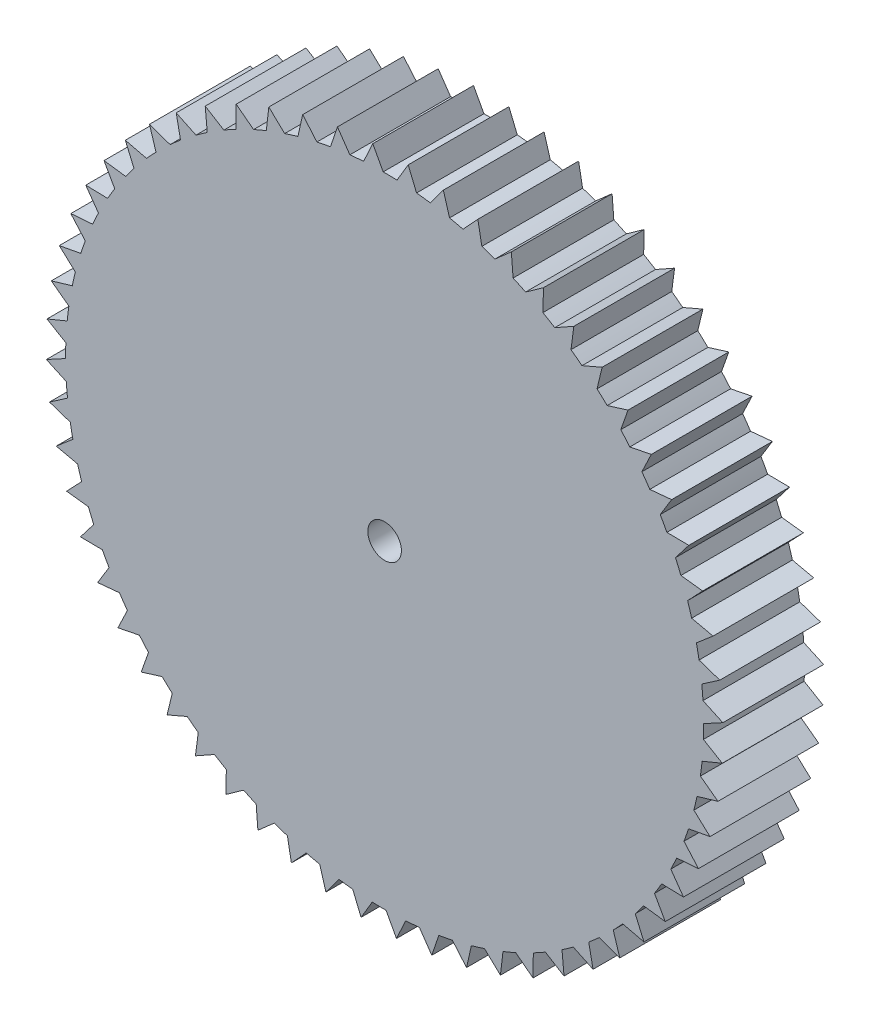
from build123d import *

# Parameters (mm, degrees)
SKETCH3_R           = 9.5
BOSS_EXTRUDE1_DEPTH = 3
SKETCH7_R           = 2
BOSS_EXTRUDE4_DEPTH = 3
BOSS_EXTRUDE5_DEPTH = 3
CIRPATTERN2_COUNT   = 20
SKETCH9_R           = 0.5
CUT_EXTRUDE1_DEPTH  = 6
BOSS_EXTRUDE6_DEPTH = 3
CIRPATTERN3_COUNT   = 60


with BuildPart() as part:
    # Sketch3 → Boss-Extrude1 (new body)
    with BuildSketch(Plane(origin=(0, 0, -25.970633743), x_dir=(-1, 0, 0), z_dir=(0, 0, -1))):
        with Locations((0, 66.2)):
            Circle(SKETCH3_R)
    extrude(amount=BOSS_EXTRUDE1_DEPTH)

    # Sketch7 → Boss-Extrude4 (add)
    with BuildSketch(Plane(origin=(0, 0, -28.970633743), x_dir=(-1, 0, 0), z_dir=(0, 0, -1))):
        with Locations((0, 66.2)):
            Circle(SKETCH7_R)
    extrude(amount=BOSS_EXTRUDE4_DEPTH)

    # Sketch8 → Boss-Extrude5 (add)
    with BuildSketch(Plane(origin=(0, 0, -31.970633743), x_dir=(-1, 0, 0), z_dir=(0, 0, -1))):
        Polygon((0.4, 64.4), (-0.4, 64.4), (0, 63.6), align=None)
    boss_extrude5 = extrude(amount=-BOSS_EXTRUDE5_DEPTH)

    # CirPattern2: Boss-Extrude5 ×20 about axis
    cirpattern2_axis = Axis((0, 66.168195033, 0), (0, 0, 1))
    for i in range(1, CIRPATTERN2_COUNT):
        add(boss_extrude5.rotate(cirpattern2_axis, i * 360 / CIRPATTERN2_COUNT))

    # Sketch9 → Cut-Extrude1 (cut)
    with BuildSketch(Plane(origin=(0, 0, -31.970633743), x_dir=(-1, 0, 0), z_dir=(0, 0, -1))):
        with Locations((0, 66.2)):
            Circle(SKETCH9_R)
    extrude(amount=-CUT_EXTRUDE1_DEPTH, mode=Mode.SUBTRACT)

    # Sketch10 → Boss-Extrude6 (add)
    with BuildSketch(Plane.XY.offset(-25.970633743)):
        Polygon((0.701380137, 76.253990752), (0.358145355, 75.67501529), (0.958491111, 75.63313435), align=None)
    boss_extrude6 = extrude(amount=-BOSS_EXTRUDE6_DEPTH)

    # CirPattern3: Boss-Extrude6 ×60 about axis
    cirpattern3_axis = Axis((0, 66.2, 0), (0, 0, 1))
    for i in range(1, CIRPATTERN3_COUNT):
        add(boss_extrude6.rotate(cirpattern3_axis, i * 360 / CIRPATTERN3_COUNT))


solid = part.part
